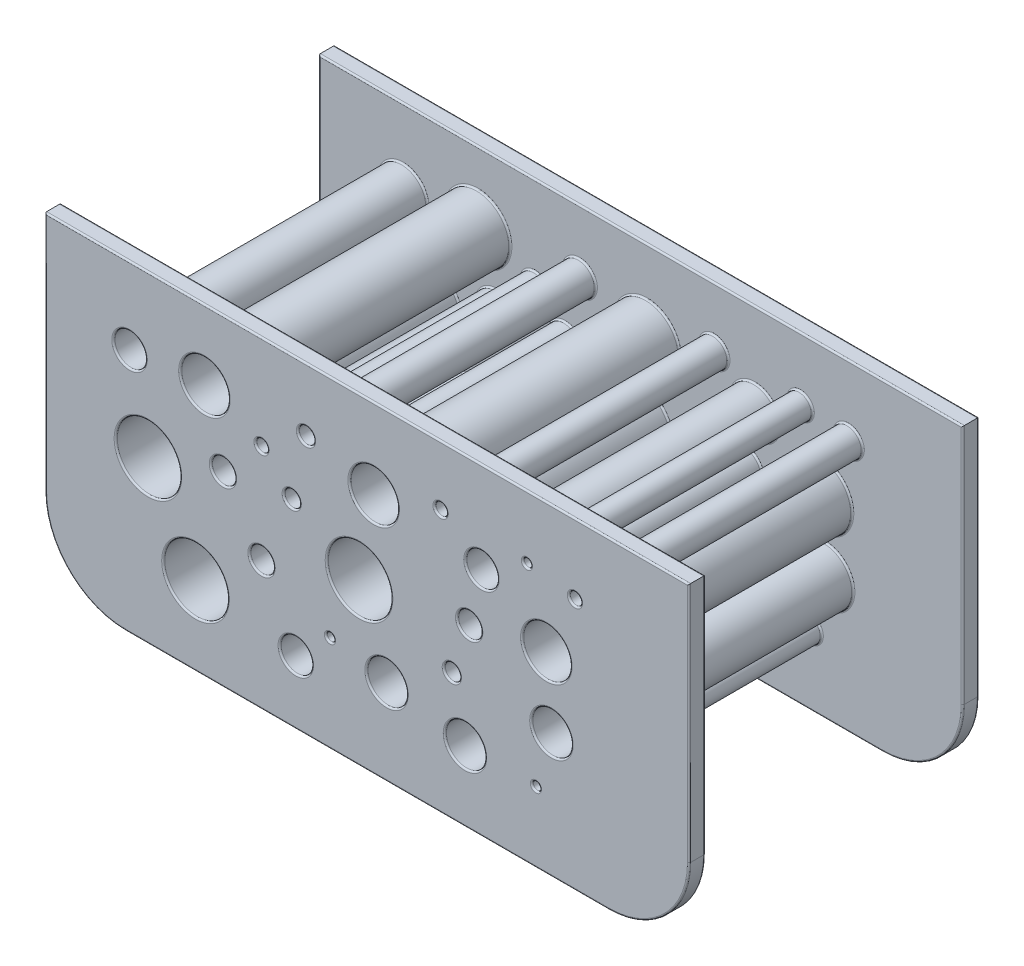
from build123d import *

# Parameters (mm, degrees)
SKIZZE1_R                            = 5
SKIZZE1_R_2                          = 4
AUFSATZ_LINEAR_AUSTRAGEN1_DEPTH      = 16
AUFSATZ_LINEAR_AUSTRAGEN1_2_DEPTH    = 16
AUFSATZ_LINEAR_AUSTRAGEN1_3_DEPTH    = 16
SKIZZE1_R_3                          = 3
AUFSATZ_LINEAR_AUSTRAGEN1_4_DEPTH    = 16
AUFSATZ_LINEAR_AUSTRAGEN1_5_DEPTH    = 16
AUFSATZ_LINEAR_AUSTRAGEN1_6_DEPTH    = 16
SKIZZE1_R_4                          = 3.5
SKIZZE1_R_5                          = 2.5
AUFSATZ_LINEAR_AUSTRAGEN1_7_DEPTH    = 16
AUFSATZ_LINEAR_AUSTRAGEN1_8_DEPTH    = 16
AUFSATZ_LINEAR_AUSTRAGEN1_9_DEPTH    = 16
SKIZZE1_R_6                          = 2
AUFSATZ_LINEAR_AUSTRAGEN1_10_DEPTH   = 16
AUFSATZ_LINEAR_AUSTRAGEN1_11_DEPTH   = 16
AUFSATZ_LINEAR_AUSTRAGEN1_12_DEPTH   = 16
SKIZZE1_R_7                          = 1.5
AUFSATZ_LINEAR_AUSTRAGEN1_13_DEPTH   = 16
AUFSATZ_LINEAR_AUSTRAGEN1_14_DEPTH   = 16
AUFSATZ_LINEAR_AUSTRAGEN1_15_DEPTH   = 16
SKIZZE1_R_8                          = 1
AUFSATZ_LINEAR_AUSTRAGEN1_16_DEPTH   = 16
AUFSATZ_LINEAR_AUSTRAGEN1_17_DEPTH   = 16
AUFSATZ_LINEAR_AUSTRAGEN1_18_DEPTH   = 16
SKIZZE1_R_9                          = 1.75
SKIZZE1_R_10                         = 0.75
AUFSATZ_LINEAR_AUSTRAGEN1_19_DEPTH   = 16
AUFSATZ_LINEAR_AUSTRAGEN1_20_DEPTH   = 16
AUFSATZ_LINEAR_AUSTRAGEN1_21_DEPTH   = 16
SKIZZE1_R_11                         = 0.5
AUFSATZ_LINEAR_AUSTRAGEN1_22_DEPTH   = 16
AUFSATZ_LINEAR_AUSTRAGEN1_23_DEPTH   = 16
AUFSATZ_LINEAR_AUSTRAGEN1_24_DEPTH   = 16
SKIZZE2_W                            = 80
SKIZZE2_H                            = 40
AUFSATZ_LINEAR_AUSTRAGEN2_DEPTH      = 2
SKIZZE3_R                            = 0.75
SKIZZE3_R_2                          = 0.5
SKIZZE3_R_3                          = 2
SKIZZE3_R_4                          = 3
SKIZZE3_R_5                          = 2.5
SKIZZE3_R_6                          = 1
SKIZZE3_R_7                          = 1.5
SKIZZE3_R_8                          = 4
SCHNITT_LINEAR_AUSTRAGEN1_DEPTH      = 1
SCHNITT_LINEAR_AUSTRAGEN1_DEPTH_BACK = 35
SKIZZE4_W                            = 80
SKIZZE4_H                            = 40
AUFSATZ_LINEAR_AUSTRAGEN3_DEPTH      = 2
SKIZZE5_R                            = 2
SKIZZE5_R_2                          = 3
SKIZZE5_R_3                          = 4
SKIZZE5_R_4                          = 1.5
SKIZZE5_R_5                          = 1
SKIZZE5_R_6                          = 0.75
SKIZZE5_R_7                          = 0.5
SKIZZE5_R_8                          = 2.5
SCHNITT_LINEAR_AUSTRAGEN2_DEPTH      = 1
SCHNITT_LINEAR_AUSTRAGEN2_DEPTH_BACK = 37
VERRUNDUNG1_R                        = 10
VERRUNDUNG2_R                        = 0.2


with BuildPart() as part:
    # Skizze1 → Aufsatz-Linear austragen1 (new body, symmetric)
    with BuildSketch(Plane.XY):
        with Locations((-1.003251847, 0)):
            Circle(SKIZZE1_R)
        with Locations((-1.003251847, 0)):
            Circle(SKIZZE1_R_2, mode=Mode.SUBTRACT)
    extrude(amount=AUFSATZ_LINEAR_AUSTRAGEN1_DEPTH, both=True)



with BuildPart() as body_2:
    # Skizze1 → Aufsatz-Linear austragen1 2 (new body, symmetric)
    with BuildSketch(Plane.XY):
        with Locations((-21.316666283, -10.198120131)):
            Circle(SKIZZE1_R)
        with Locations((-21.316666283, -10.198120131)):
            Circle(SKIZZE1_R_2, mode=Mode.SUBTRACT)
    extrude(amount=AUFSATZ_LINEAR_AUSTRAGEN1_2_DEPTH, both=True)


with BuildPart() as body_3:
    # Skizze1 → Aufsatz-Linear austragen1 3 (new body, symmetric)
    with BuildSketch(Plane.XY):
        with Locations((-27.220755987, 0)):
            Circle(SKIZZE1_R)
        with Locations((-27.220755987, 0)):
            Circle(SKIZZE1_R_2, mode=Mode.SUBTRACT)
    extrude(amount=AUFSATZ_LINEAR_AUSTRAGEN1_3_DEPTH, both=True)


with BuildPart() as body_4:
    # Skizze1 → Aufsatz-Linear austragen1 4 (new body, symmetric)
    with BuildSketch(Plane.XY):
        with Locations((22.262501453, 3.877279919)):
            Circle(SKIZZE1_R_2)
        with Locations((22.262501453, 3.877279919)):
            Circle(SKIZZE1_R_3, mode=Mode.SUBTRACT)
    extrude(amount=AUFSATZ_LINEAR_AUSTRAGEN1_4_DEPTH, both=True)


with BuildPart() as body_5:
    # Skizze1 → Aufsatz-Linear austragen1 5 (new body, symmetric)
    with BuildSketch(Plane.XY):
        with Locations((-20.207447217, 11.318570909)):
            Circle(SKIZZE1_R_2)
        with Locations((-20.207447217, 11.318570909)):
            Circle(SKIZZE1_R_3, mode=Mode.SUBTRACT)
    extrude(amount=AUFSATZ_LINEAR_AUSTRAGEN1_5_DEPTH, both=True)


with BuildPart() as body_6:
    # Skizze1 → Aufsatz-Linear austragen1 6 (new body, symmetric)
    with BuildSketch(Plane.XY):
        with Locations((0.8172778, 10.031678423)):
            Circle(SKIZZE1_R_2)
        with Locations((0.8172778, 10.031678423)):
            Circle(SKIZZE1_R_3, mode=Mode.SUBTRACT)
    extrude(amount=AUFSATZ_LINEAR_AUSTRAGEN1_6_DEPTH, both=True)


with BuildPart() as body_7:
    # Skizze1 → Aufsatz-Linear austragen1 7 (new body, symmetric)
    with BuildSketch(Plane.XY):
        with Locations((22.895160703, -4.532639836)):
            Circle(SKIZZE1_R_4)
        with Locations((22.895160703, -4.532639836)):
            Circle(SKIZZE1_R_5, mode=Mode.SUBTRACT)
    extrude(amount=AUFSATZ_LINEAR_AUSTRAGEN1_7_DEPTH, both=True)


with BuildPart() as body_8:
    # Skizze1 → Aufsatz-Linear austragen1 8 (new body, symmetric)
    with BuildSketch(Plane.XY):
        with Locations((12.156670283, -11.253472024)):
            Circle(SKIZZE1_R_4)
        with Locations((12.156670283, -11.253472024)):
            Circle(SKIZZE1_R_5, mode=Mode.SUBTRACT)
    extrude(amount=AUFSATZ_LINEAR_AUSTRAGEN1_8_DEPTH, both=True)


with BuildPart() as body_9:
    # Skizze1 → Aufsatz-Linear austragen1 9 (new body, symmetric)
    with BuildSketch(Plane.XY):
        with Locations((2.416422606, -9.358673056)):
            Circle(SKIZZE1_R_4)
        with Locations((2.416422606, -9.358673056)):
            Circle(SKIZZE1_R_5, mode=Mode.SUBTRACT)
    extrude(amount=AUFSATZ_LINEAR_AUSTRAGEN1_9_DEPTH, both=True)


with BuildPart() as body_10:
    # Skizze1 → Aufsatz-Linear austragen1 10 (new body, symmetric)
    with BuildSketch(Plane.XY):
        with Locations((-8.855837628, -12.081747157)):
            Circle(SKIZZE1_R_3)
        with Locations((-8.855837628, -12.081747157)):
            Circle(SKIZZE1_R_6, mode=Mode.SUBTRACT)
    extrude(amount=AUFSATZ_LINEAR_AUSTRAGEN1_10_DEPTH, both=True)


with BuildPart() as body_11:
    # Skizze1 → Aufsatz-Linear austragen1 11 (new body, symmetric)
    with BuildSketch(Plane.XY):
        with Locations((-29.509505764, 10.479593265)):
            Circle(SKIZZE1_R_3)
        with Locations((-29.509505764, 10.479593265)):
            Circle(SKIZZE1_R_6, mode=Mode.SUBTRACT)
    extrude(amount=AUFSATZ_LINEAR_AUSTRAGEN1_11_DEPTH, both=True)


with BuildPart() as body_12:
    # Skizze1 → Aufsatz-Linear austragen1 12 (new body, symmetric)
    with BuildSketch(Plane.XY):
        with Locations((14.204680731, 8.699282871)):
            Circle(SKIZZE1_R_3)
        with Locations((14.204680731, 8.699282871)):
            Circle(SKIZZE1_R_6, mode=Mode.SUBTRACT)
    extrude(amount=AUFSATZ_LINEAR_AUSTRAGEN1_12_DEPTH, both=True)


with BuildPart() as body_13:
    # Skizze1 → Aufsatz-Linear austragen1 13 (new body, symmetric)
    with BuildSketch(Plane.XY):
        with Locations((12.681942957, 1.973857702)):
            Circle(SKIZZE1_R_5)
        with Locations((12.681942957, 1.973857702)):
            Circle(SKIZZE1_R_7, mode=Mode.SUBTRACT)
    extrude(amount=AUFSATZ_LINEAR_AUSTRAGEN1_13_DEPTH, both=True)


with BuildPart() as body_14:
    # Skizze1 → Aufsatz-Linear austragen1 14 (new body, symmetric)
    with BuildSketch(Plane.XY):
        with Locations((-13.11577882, -3.975852157)):
            Circle(SKIZZE1_R_5)
        with Locations((-13.11577882, -3.975852157)):
            Circle(SKIZZE1_R_7, mode=Mode.SUBTRACT)
    extrude(amount=AUFSATZ_LINEAR_AUSTRAGEN1_14_DEPTH, both=True)


with BuildPart() as body_15:
    # Skizze1 → Aufsatz-Linear austragen1 15 (new body, symmetric)
    with BuildSketch(Plane.XY):
        with Locations((-17.904957478, 3.203725688)):
            Circle(SKIZZE1_R_5)
        with Locations((-17.904957478, 3.203725688)):
            Circle(SKIZZE1_R_7, mode=Mode.SUBTRACT)
    extrude(amount=AUFSATZ_LINEAR_AUSTRAGEN1_15_DEPTH, both=True)


with BuildPart() as body_16:
    # Skizze1 → Aufsatz-Linear austragen1 16 (new body, symmetric)
    with BuildSketch(Plane.XY):
        with Locations((10.529294962, -4.211717985)):
            Circle(SKIZZE1_R_6)
        with Locations((10.529294962, -4.211717985)):
            Circle(SKIZZE1_R_8, mode=Mode.SUBTRACT)
    extrude(amount=AUFSATZ_LINEAR_AUSTRAGEN1_16_DEPTH, both=True)


with BuildPart() as body_17:
    # Skizze1 → Aufsatz-Linear austragen1 17 (new body, symmetric)
    with BuildSketch(Plane.XY):
        with Locations((-7.589803446, 12.18889027)):
            Circle(SKIZZE1_R_6)
        with Locations((-7.589803446, 12.18889027)):
            Circle(SKIZZE1_R_8, mode=Mode.SUBTRACT)
    extrude(amount=AUFSATZ_LINEAR_AUSTRAGEN1_17_DEPTH, both=True)


with BuildPart() as body_18:
    # Skizze1 → Aufsatz-Linear austragen1 18 (new body, symmetric)
    with BuildSketch(Plane.XY):
        with Locations((-9.362456066, 4.51000667)):
            Circle(SKIZZE1_R_6)
        with Locations((-9.362456066, 4.51000667)):
            Circle(SKIZZE1_R_8, mode=Mode.SUBTRACT)
    extrude(amount=AUFSATZ_LINEAR_AUSTRAGEN1_18_DEPTH, both=True)


with BuildPart() as body_19:
    # Skizze1 → Aufsatz-Linear austragen1 19 (new body, symmetric)
    with BuildSketch(Plane.XY):
        with Locations((-13.11577882, 8.318570909)):
            Circle(SKIZZE1_R_9)
        with Locations((-13.11577882, 8.318570909)):
            Circle(SKIZZE1_R_10, mode=Mode.SUBTRACT)
    extrude(amount=AUFSATZ_LINEAR_AUSTRAGEN1_19_DEPTH, both=True)


with BuildPart() as body_20:
    # Skizze1 → Aufsatz-Linear austragen1 20 (new body, symmetric)
    with BuildSketch(Plane.XY):
        with Locations((9.128355296, 12.607866338)):
            Circle(SKIZZE1_R_9)
        with Locations((9.128355296, 12.607866338)):
            Circle(SKIZZE1_R_10, mode=Mode.SUBTRACT)
    extrude(amount=AUFSATZ_LINEAR_AUSTRAGEN1_20_DEPTH, both=True)


with BuildPart() as body_21:
    # Skizze1 → Aufsatz-Linear austragen1 21 (new body, symmetric)
    with BuildSketch(Plane.XY):
        with Locations((25.815556259, 11.318570909)):
            Circle(SKIZZE1_R_9)
        with Locations((25.815556259, 11.318570909)):
            Circle(SKIZZE1_R_10, mode=Mode.SUBTRACT)
    extrude(amount=AUFSATZ_LINEAR_AUSTRAGEN1_21_DEPTH, both=True)


with BuildPart() as body_22:
    # Skizze1 → Aufsatz-Linear austragen1 22 (new body, symmetric)
    with BuildSketch(Plane.XY):
        with Locations((19.851499977, 12.18889027)):
            Circle(SKIZZE1_R_7)
        with Locations((19.851499977, 12.18889027)):
            Circle(SKIZZE1_R_11, mode=Mode.SUBTRACT)
    extrude(amount=AUFSATZ_LINEAR_AUSTRAGEN1_22_DEPTH, both=True)


with BuildPart() as body_23:
    # Skizze1 → Aufsatz-Linear austragen1 23 (new body, symmetric)
    with BuildSketch(Plane.XY):
        with Locations((20.971322878, -11.253472024)):
            Circle(SKIZZE1_R_7)
        with Locations((20.971322878, -11.253472024)):
            Circle(SKIZZE1_R_11, mode=Mode.SUBTRACT)
    extrude(amount=AUFSATZ_LINEAR_AUSTRAGEN1_23_DEPTH, both=True)


with BuildPart() as body_24:
    # Skizze1 → Aufsatz-Linear austragen1 24 (new body, symmetric)
    with BuildSketch(Plane.XY):
        with Locations((-4.612908215, -8.028799657)):
            Circle(SKIZZE1_R_7)
        with Locations((-4.612908215, -8.028799657)):
            Circle(SKIZZE1_R_11, mode=Mode.SUBTRACT)
    extrude(amount=AUFSATZ_LINEAR_AUSTRAGEN1_24_DEPTH, both=True)


with BuildPart() as part_1:
    add(part.part)

    add(body_2.part)  # Aufsatz-Linear austragen2 merges body 2

    add(body_3.part)  # Aufsatz-Linear austragen2 merges body 3

    add(body_4.part)  # Aufsatz-Linear austragen2 merges body 4

    add(body_5.part)  # Aufsatz-Linear austragen2 merges body 5

    add(body_6.part)  # Aufsatz-Linear austragen2 merges body 6

    add(body_7.part)  # Aufsatz-Linear austragen2 merges body 7

    add(body_8.part)  # Aufsatz-Linear austragen2 merges body 8

    add(body_9.part)  # Aufsatz-Linear austragen2 merges body 9

    add(body_10.part)  # Aufsatz-Linear austragen2 merges body 10

    add(body_11.part)  # Aufsatz-Linear austragen2 merges body 11

    add(body_12.part)  # Aufsatz-Linear austragen2 merges body 12

    add(body_13.part)  # Aufsatz-Linear austragen2 merges body 13

    add(body_14.part)  # Aufsatz-Linear austragen2 merges body 14

    add(body_15.part)  # Aufsatz-Linear austragen2 merges body 15

    add(body_16.part)  # Aufsatz-Linear austragen2 merges body 16

    add(body_17.part)  # Aufsatz-Linear austragen2 merges body 17

    add(body_18.part)  # Aufsatz-Linear austragen2 merges body 18

    add(body_19.part)  # Aufsatz-Linear austragen2 merges body 19

    add(body_20.part)  # Aufsatz-Linear austragen2 merges body 20

    add(body_21.part)  # Aufsatz-Linear austragen2 merges body 21

    add(body_22.part)  # Aufsatz-Linear austragen2 merges body 22

    add(body_23.part)  # Aufsatz-Linear austragen2 merges body 23

    add(body_24.part)  # Aufsatz-Linear austragen2 merges body 24
    # Skizze2 → Aufsatz-Linear austragen2 (add)
    with BuildSketch(Plane.XY.offset(16)):
        Rectangle(SKIZZE2_W, SKIZZE2_H)
    extrude(amount=AUFSATZ_LINEAR_AUSTRAGEN2_DEPTH)

    # Skizze3 → Schnitt-Linear austragen1 (cut, two sides)
    with BuildSketch(Plane(origin=(0, 0, -16), x_dir=(-1, 0, 0), z_dir=(0, 0, -1))) as schnitt_linear_austragen1_sk:
        with Locations((-25.815556259, 11.318570909)):
            Circle(SKIZZE3_R)
        with Locations((-19.851499977, 12.18889027)):
            Circle(SKIZZE3_R_2)
        with Locations((-9.128355296, 12.607866338)):
            Circle(SKIZZE3_R)
        with Locations((-14.204680731, 8.699282871)):
            Circle(SKIZZE3_R_3)
        with Locations((-22.262501453, 3.877279919)):
            Circle(SKIZZE3_R_4)
        with Locations((-22.895160703, -4.532639836)):
            Circle(SKIZZE3_R_5)
        with Locations((-20.971322878, -11.253472024)):
            Circle(SKIZZE3_R_2)
        with Locations((-12.156670283, -11.253472024)):
            Circle(SKIZZE3_R_5)
        with Locations((-10.529294962, -4.211717985)):
            Circle(SKIZZE3_R_6)
        with Locations((-12.681942957, 1.973857702)):
            Circle(SKIZZE3_R_7)
        with Locations((1.003251847, 0)):
            Circle(SKIZZE3_R_8)
        with Locations((-2.416422606, -9.358673056)):
            Circle(SKIZZE3_R_5)
        with Locations((4.612908215, -8.028799657)):
            Circle(SKIZZE3_R_2)
        with Locations((8.855837628, -12.081747157)):
            Circle(SKIZZE3_R_3)
        with Locations((21.316666283, -10.198120131)):
            Circle(SKIZZE3_R_8)
        with Locations((13.11577882, -3.975852157)):
            Circle(SKIZZE3_R_7)
        with Locations((27.220755987, 0)):
            Circle(SKIZZE3_R_8)
        with Locations((17.904957478, 3.203725688)):
            Circle(SKIZZE3_R_7)
        with Locations((9.362456066, 4.51000667)):
            Circle(SKIZZE3_R_6)
        with Locations((13.11577882, 8.318570909)):
            Circle(SKIZZE3_R)
        with Locations((7.589803446, 12.18889027)):
            Circle(SKIZZE3_R_6)
        with Locations((-0.8172778, 10.031678423)):
            Circle(SKIZZE3_R_4)
        with Locations((20.207447217, 11.318570909)):
            Circle(SKIZZE3_R_4)
        with Locations((29.509505764, 10.479593265)):
            Circle(SKIZZE3_R_3)
    extrude(amount=SCHNITT_LINEAR_AUSTRAGEN1_DEPTH, mode=Mode.SUBTRACT)
    extrude(schnitt_linear_austragen1_sk.sketch, amount=-SCHNITT_LINEAR_AUSTRAGEN1_DEPTH_BACK, mode=Mode.SUBTRACT)

    # Skizze4 → Aufsatz-Linear austragen3 (add)
    with BuildSketch(Plane(origin=(0, 0, -16), x_dir=(-1, 0, 0), z_dir=(0, 0, -1))):
        Rectangle(SKIZZE4_W, SKIZZE4_H)
    extrude(amount=AUFSATZ_LINEAR_AUSTRAGEN3_DEPTH)

    # Skizze5 → Schnitt-Linear austragen2 (cut, two sides)
    with BuildSketch(Plane.XY.offset(18)) as schnitt_linear_austragen2_sk:
        with Locations((-29.509505764, 10.479593265)):
            Circle(SKIZZE5_R)
        with Locations((-20.207447217, 11.318570909)):
            Circle(SKIZZE5_R_2)
        with Locations((-27.220755987, 0)):
            Circle(SKIZZE5_R_3)
        with Locations((-21.316666283, -10.198120131)):
            Circle(SKIZZE5_R_3)
        with Locations((-17.904957478, 3.203725688)):
            Circle(SKIZZE5_R_4)
        with Locations((-13.11577882, -3.975852157)):
            Circle(SKIZZE5_R_4)
        with Locations((-8.855837628, -12.081747157)):
            Circle(SKIZZE5_R)
        with Locations((-1.003251847, 0)):
            Circle(SKIZZE5_R_3)
        with Locations((-9.362456066, 4.51000667)):
            Circle(SKIZZE5_R_5)
        with Locations((-13.11577882, 8.318570909)):
            Circle(SKIZZE5_R_6)
        with Locations((-7.589803446, 12.18889027)):
            Circle(SKIZZE5_R_5)
        with Locations((0.8172778, 10.031678423)):
            Circle(SKIZZE5_R_2)
        with Locations((9.128355296, 12.607866338)):
            Circle(SKIZZE5_R_6)
        with Locations((14.204680731, 8.699282871)):
            Circle(SKIZZE5_R)
        with Locations((12.681942957, 1.973857702)):
            Circle(SKIZZE5_R_4)
        with Locations((-4.612908215, -8.028799657)):
            Circle(SKIZZE5_R_7)
        with Locations((2.416422606, -9.358673056)):
            Circle(SKIZZE5_R_8)
        with Locations((10.529294962, -4.211717985)):
            Circle(SKIZZE5_R_5)
        with Locations((12.156670283, -11.253472024)):
            Circle(SKIZZE5_R_8)
        with Locations((20.971322878, -11.253472024)):
            Circle(SKIZZE5_R_7)
        with Locations((22.895160703, -4.532639836)):
            Circle(SKIZZE5_R_8)
        with Locations((22.262501453, 3.877279919)):
            Circle(SKIZZE5_R_2)
        with Locations((25.815556259, 11.318570909)):
            Circle(SKIZZE5_R_6)
        with Locations((19.851499977, 12.18889027)):
            Circle(SKIZZE5_R_7)
    extrude(amount=SCHNITT_LINEAR_AUSTRAGEN2_DEPTH, mode=Mode.SUBTRACT)
    extrude(schnitt_linear_austragen2_sk.sketch, amount=-SCHNITT_LINEAR_AUSTRAGEN2_DEPTH_BACK, mode=Mode.SUBTRACT)

    # Verrundung1
    verrundung1_edges = [part_1.edges().sort_by_distance(p)[0] for p in [
        (40, -20, 17),
        (-40, -20, 17),
        (-40, -20, -17),
        (40, -20, -17),
    ]]
    fillet(verrundung1_edges, radius=VERRUNDUNG1_R)

    # Verrundung2
    verrundung2_edges = [part_1.edges().sort_by_distance(p)[0] for p in [
        (0, 20, 16),
        (-11.362456066, 4.51000667, 16),
        (-40, 5, 16),
        (-14.86577882, 8.318570909, 16),
        (7.378355296, 12.607866338, 16),
        (0, 20, 18),
        (24.065556259, 11.318570909, 16),
        (-40, 5, 18),
        (18.351499977, 12.18889027, 16),
        (19.471322878, -11.253472024, 16),
        (-6.112908215, -8.028799657, 16),
        (-27.220755987, 4, 18),
        (-13.11577882, -2.475852157, 18),
        (-21.316666283, -6.198120131, 18),
        (-8.855837628, -10.081747157, 18),
        (-4.612908215, -7.528799657, 18),
        (2.416422606, -6.858673056, 18),
        (-1.003251847, 4, 18),
        (12.681942957, 3.473857702, 18),
        (10.529294962, -3.211717985, 18),
        (12.156670283, -8.753472024, 18),
        (20.971322878, -10.753472024, 18),
        (22.895160703, -2.032639836, 18),
        (22.262501453, 6.877279919, 18),
        (14.204680731, 10.699282871, 18),
        (9.128355296, 13.357866338, 18),
        (19.851499977, 12.68889027, 18),
        (-29.509505764, 12.479593265, 18),
        (-26.316666283, -10.198120131, 16),
        (-20.207447217, 14.318570909, 18),
        (0.8172778, 13.031678423, 18),
        (-7.589803446, 13.18889027, 18),
        (-13.11577882, 9.068570909, 18),
        (-9.362456066, 5.51000667, 18),
        (-17.904957478, 4.703725688, 18),
        (25.815556259, 12.068570909, 18),
        (-32.220755987, 0, 16),
        (-6.003251847, 0, -16),
        (-26.316666283, -10.198120131, -16),
        (-32.220755987, 0, -16),
        (18.262501453, 3.877279919, -16),
        (-24.207447217, 11.318570909, -16),
        (-3.1827222, 10.031678423, -16),
        (19.395160703, -4.532639836, -16),
        (8.656670283, -11.253472024, -16),
        (-1.083577394, -9.358673056, -16),
        (-11.855837628, -12.081747157, -16),
        (-32.509505764, 10.479593265, -16),
        (11.204680731, 8.699282871, -16),
        (10.181942957, 1.973857702, -16),
        (-15.61577882, -3.975852157, -16),
        (-20.404957478, 3.203725688, -16),
        (8.529294962, -4.211717985, -16),
        (-9.589803446, 12.18889027, -16),
        (-11.362456066, 4.51000667, -16),
        (-14.86577882, 8.318570909, -16),
        (7.378355296, 12.607866338, -16),
        (24.065556259, 11.318570909, -16),
        (18.351499977, 12.18889027, -16),
        (19.471322878, -11.253472024, -16),
        (-6.112908215, -8.028799657, -16),
        (0, 20, -16),
        (40, 5, -16),
        (0, 20, -18),
        (40, 5, -18),
        (18.262501453, 3.877279919, 16),
        (-13.86577882, 8.318570909, -18),
        (-24.207447217, 11.318570909, 16),
        (-8.589803446, 12.18889027, -18),
        (-2.1827222, 10.031678423, -18),
        (8.378355296, 12.607866338, -18),
        (12.204680731, 8.699282871, -18),
        (11.181942957, 1.973857702, -18),
        (-5.112908215, -8.028799657, -18),
        (-0.083577394, -9.358673056, -18),
        (-14.61577882, -3.975852157, -18),
        (-10.855837628, -12.081747157, -18),
        (-5.003251847, 0, -18),
        (-10.362456066, 4.51000667, -18),
        (-23.207447217, 11.318570909, -18),
        (-31.220755987, 0, -18),
        (-25.316666283, -10.198120131, -18),
        (-19.404957478, 3.203725688, -18),
        (9.529294962, -4.211717985, -18),
        (9.656670283, -11.253472024, -18),
        (-3.1827222, 10.031678423, 16),
        (20.471322878, -11.253472024, -18),
        (20.395160703, -4.532639836, -18),
        (19.351499977, 12.18889027, -18),
        (25.065556259, 11.318570909, -18),
        (19.262501453, 3.877279919, -18),
        (-31.509505764, 10.479593265, -18),
        (19.395160703, -4.532639836, 16),
        (0, -20, 16),
        (0, -20, 18),
        (40, 5, 16),
        (37.071067812, -17.071067812, 16),
        (-37.071067812, -17.071067812, 16),
        (40, 5, 18),
        (37.071067812, -17.071067812, 18),
        (-37.071067812, -17.071067812, 18),
        (-40, 5, -16),
        (-40, 5, -18),
        (0, -20, -16),
        (37.071067812, -17.071067812, -16),
        (-37.071067812, -17.071067812, -16),
        (0, -20, -18),
        (37.071067812, -17.071067812, -18),
        (-37.071067812, -17.071067812, -18),
        (-6.003251847, 0, 16),
        (8.656670283, -11.253472024, 16),
        (-1.083577394, -9.358673056, 16),
        (-11.855837628, -12.081747157, 16),
        (-32.509505764, 10.479593265, 16),
        (11.204680731, 8.699282871, 16),
        (10.181942957, 1.973857702, 16),
        (-15.61577882, -3.975852157, 16),
        (-20.404957478, 3.203725688, 16),
        (8.529294962, -4.211717985, 16),
        (-9.589803446, 12.18889027, 16),
    ]]
    fillet(verrundung2_edges, radius=VERRUNDUNG2_R)


solid = part_1.part
